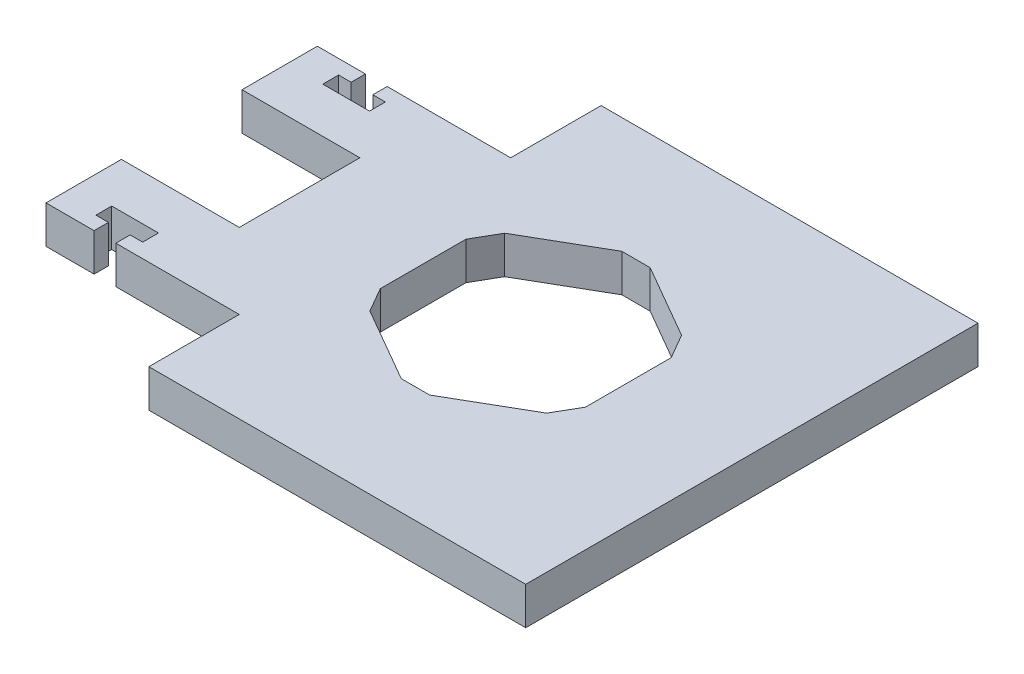
from build123d import *

# Parameters (mm, degrees)
BOSS_EXTRUDE1_DEPTH = 6.35


with BuildPart() as part:
    # Sketch1 → Boss-Extrude1 (new body)
    with BuildSketch(Plane(origin=(0, 0, 0), x_dir=(1, 0, 0), z_dir=(0, 1, 0))):
        Polygon((-25.4, -38.1), (38.1, -38.1), (38.1, 38.1), (-25.4, 38.1), (-25.4, 22.86), (-38.1, 22.86), (-46.2026, 22.86), (-46.2026, 20.447), (-44.0944, 20.447), (-44.0944, 17.78), (-51.9684, 17.78), (-51.9684, 20.447), (-49.8602, 20.447), (-49.8602, 22.86), (-57.9628, 22.86), (-57.9628, 10.16), (-38.1, 10.16), (-38.1, -10.16), (-57.9628, -10.16), (-57.9628, -22.86), (-49.8602, -22.86), (-49.8602, -20.447), (-51.9684, -20.447), (-51.9684, -17.78), (-44.0944, -17.78), (-44.0944, -20.447), (-46.2026, -20.447), (-46.2026, -22.86), (-38.1, -22.86), (-25.4, -22.86), align=None)
        Polygon((-2.389310714, -18.580574179), (2.389310714, -18.580574179), (14.896593899, -11.359490865), (17.285904613, -7.221083314), (17.285904613, 7.221083314), (14.896593899, 11.359490865), (2.389310714, 18.580574179), (-2.389310714, 18.580574179), (-14.896593899, 11.359490865), (-17.285904613, 7.221083314), (-17.285904613, -7.221083314), (-14.896593899, -11.359490865), align=None, mode=Mode.SUBTRACT)
    extrude(amount=-BOSS_EXTRUDE1_DEPTH)


solid = part.part
